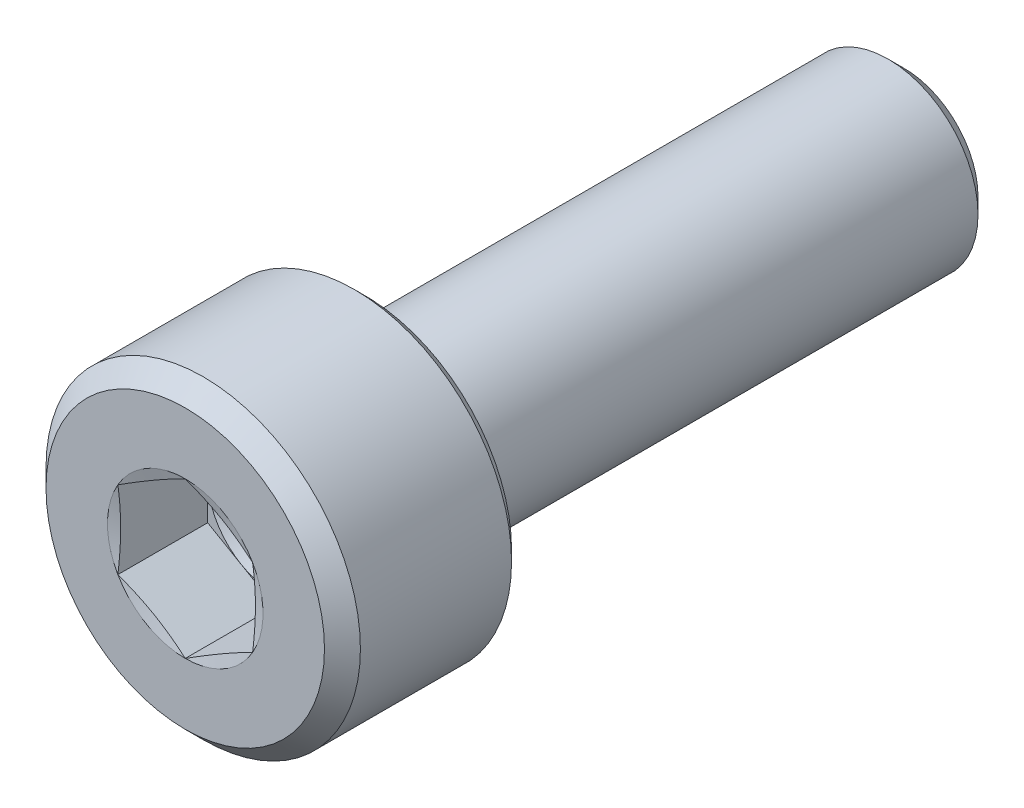
from build123d import *

# Parameters (mm, degrees)
CUT_EXTRUDE1_DEPTH = 2


with BuildPart() as part:
    # Sketch1 → Revolve1 (revolve)
    with BuildSketch(Plane(origin=(0, 0, 0), x_dir=(0, 0, -1), z_dir=(1, 0, 0))):
        with BuildLine():
            Line((0, 0), (0, 3.1))
            Line((0, 3.1), (0.4, 3.5))
            Line((0.4, 3.5), (3.765, 3.5))
            Line((3.765, 3.5), (4, 3.265))
            Line((4, 3.265), (4, 2.35))
            ThreePointArc((4, 2.35), (4.035614876, 2.236081032), (4.129775312, 2.162734164))
            Line((4.129775312, 2.162734164), (4.529775312, 2.012734164))
            ThreePointArc((4.529775312, 2.012734164), (4.564315039, 2.00320929), (4.6, 2))
            Line((4.6, 2), (15.65, 2))
            Line((15.65, 2), (16, 1.65))
            Line((16, 1.65), (16, 0))
            Line((16, 0), (0, 0))
        make_face()
    revolve(axis=Axis((0, 0, 0), (0, 0, -1)))

    # Sketch2 → Cut-Extrude1 (cut)
    with BuildSketch(Plane.XY):
        Polygon((0, 1.732050808), (-1.5, 0.866025404), (-1.5, -0.866025404), (0, -1.732050808), (1.5, -0.866025404), (1.5, 0.866025404), align=None)
    extrude(amount=-CUT_EXTRUDE1_DEPTH, mode=Mode.SUBTRACT)

    # Sketch3 → Cut-Revolve2 (revolve, cut)
    with BuildSketch(Plane(origin=(0, 0, 0), x_dir=(0, 0, -1), z_dir=(1, 0, 0))):
        Polygon((2, 0), (2, 1.5), (2.866025404, 0), align=None)
    revolve(axis=Axis((0, 0, -2), (0, 0, -1)), mode=Mode.SUBTRACT)

    # Sketch4 → Cut-Revolve3 (revolve, cut)
    with BuildSketch(Plane(origin=(0, 0, 0), x_dir=(0, 0, -1), z_dir=(1, 0, 0))):
        Polygon((0, 1.732050808), (0, 1.5), (0.062177826, 1.5), align=None)
    revolve(axis=Axis((0, 0, 0), (0, 0, -1)), mode=Mode.SUBTRACT)


solid = part.part
